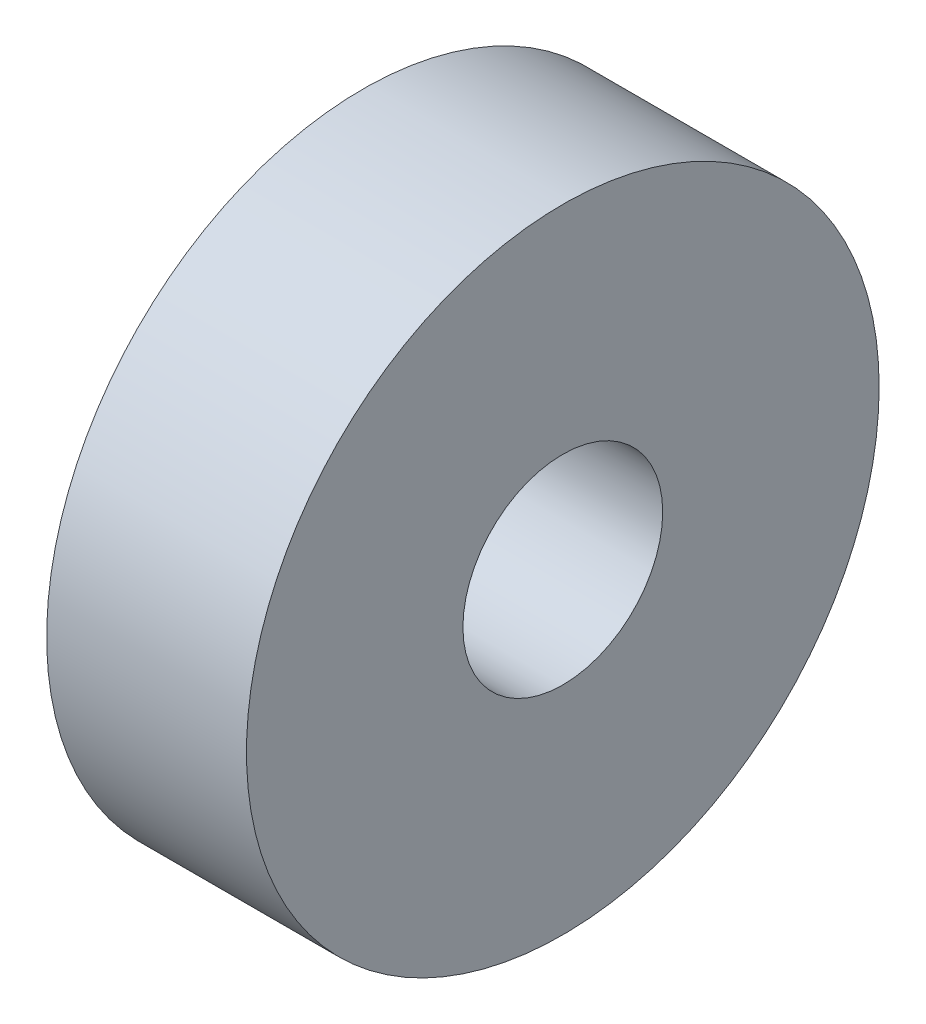
from build123d import *

# Parameters (mm, degrees)
SKETCH1_R           = 9.5
SKETCH1_R_2         = 3
BOSS_EXTRUDE1_DEPTH = 6


with BuildPart() as part:
    # Sketch1 → Boss-Extrude1 (new body)
    with BuildSketch(Plane(origin=(0, 0, 0), x_dir=(0, 0, -1), z_dir=(1, 0, 0))):
        Circle(SKETCH1_R)
        Circle(SKETCH1_R_2, mode=Mode.SUBTRACT)
    extrude(amount=BOSS_EXTRUDE1_DEPTH)


solid = part.part
